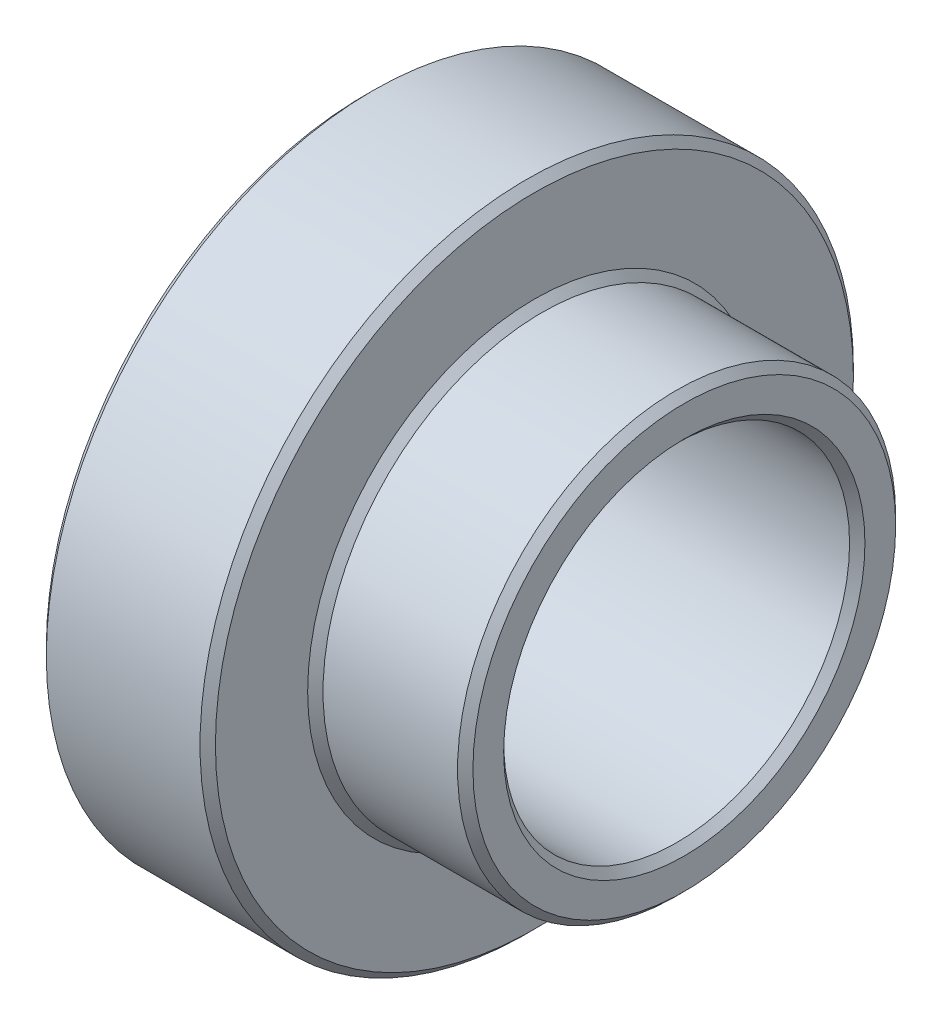
from build123d import *

# Parameters (mm, degrees)
CHAMFER1_SIZE = 1


with BuildPart() as part:
    # Sketch1 → Revolve1 (revolve)
    with BuildSketch(Plane.XY):
        Polygon((0, 22.5), (0, 42.5), (22, 42.5), (22, 28.5), (41.5, 28.5), (41.5, 22.5), align=None)
    revolve(axis=Axis((43.575, 0, 0), (-1, 0, 0)))

    # Chamfer1
    chamfer1_edges = [part.edges().sort_by_distance(p)[0] for p in [
        (0, -42.5, 0),
        (0, -22.5, 0),
        (41.5, -22.5, 0),
        (41.5, -28.5, 0),
        (22, -28.5, 0),
        (22, -42.5, 0),
    ]]
    chamfer(chamfer1_edges, length=CHAMFER1_SIZE)


solid = part.part
